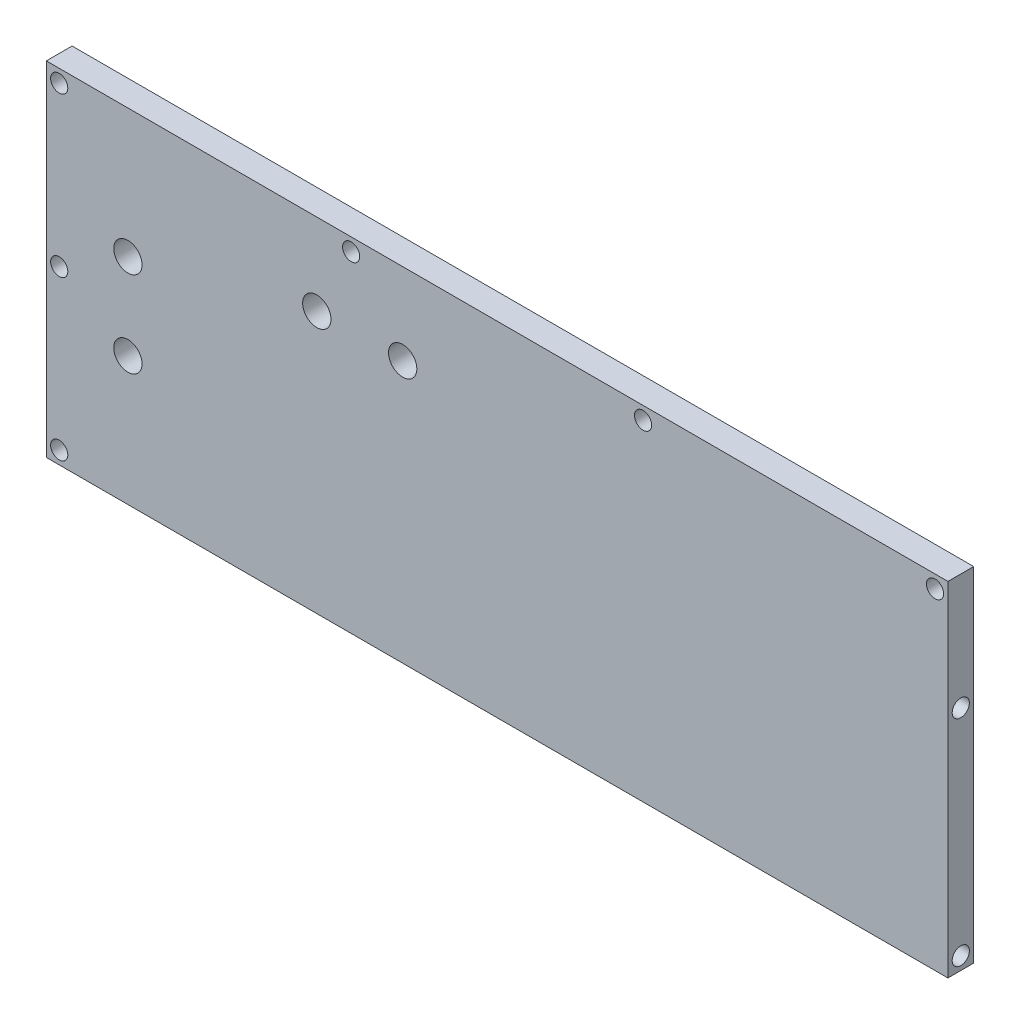
from build123d import *

# Parameters (mm, degrees)
SKETCH_1_W          = 210
SKETCH_1_H          = 80
EXTRUDE_1_DEPTH     = 6
SKETCH_2_R          = 2
CUT_EXTRUDE_1_DEPTH = 6
SKETCH_3_R          = 2
CUT_EXTRUDE_2_DEPTH = 20
SKETCH_4_R          = 3.3
CUT_EXTRUDE_3_DEPTH = 10
SKETCH_5_R          = 3.3
CUT_EXTRUDE_4_DEPTH = 10


with BuildPart() as part:
    # 草图1 → 凸台-拉伸1 (new body)
    with BuildSketch(Plane.XY):
        Rectangle(SKETCH_1_W, SKETCH_1_H)
    extrude(amount=EXTRUDE_1_DEPTH)

    # 草图2 → 切除-拉伸1 (cut)
    with BuildSketch(Plane.XY.offset(6)):
        with Locations((-102, 0)):
            Circle(SKETCH_2_R)
        with Locations((-102, 37)):
            Circle(SKETCH_2_R)
        with Locations((-102, -37)):
            Circle(SKETCH_2_R)
        with Locations((-34, 37)):
            Circle(SKETCH_2_R)
        with Locations((34, 37)):
            Circle(SKETCH_2_R)
        with Locations((102, 37)):
            Circle(SKETCH_2_R)
    extrude(amount=-CUT_EXTRUDE_1_DEPTH, mode=Mode.SUBTRACT)

    # 草图3 → 切除-拉伸2 (cut)
    with BuildSketch(Plane(origin=(105, 0, 0), x_dir=(0, 0, -1), z_dir=(1, 0, 0))):
        with Locations((-3, -37)):
            Circle(SKETCH_3_R)
        with Locations((-3, 13)):
            Circle(SKETCH_3_R)
    extrude(amount=-CUT_EXTRUDE_2_DEPTH, mode=Mode.SUBTRACT)

    # 草图4 → 切除-拉伸3 (cut)
    with BuildSketch(Plane.XY.offset(6)):
        with Locations((-86, 10)):
            Circle(SKETCH_4_R)
        with Locations((-86, -10)):
            Circle(SKETCH_4_R)
    extrude(amount=-CUT_EXTRUDE_3_DEPTH, mode=Mode.SUBTRACT)

    # 草图5 → 切除-拉伸4 (cut)
    with BuildSketch(Plane.XY.offset(6)):
        with Locations((-42, 21)):
            Circle(SKETCH_5_R)
        with Locations((-22, 21)):
            Circle(SKETCH_5_R)
    extrude(amount=-CUT_EXTRUDE_4_DEPTH, mode=Mode.SUBTRACT)


solid = part.part
